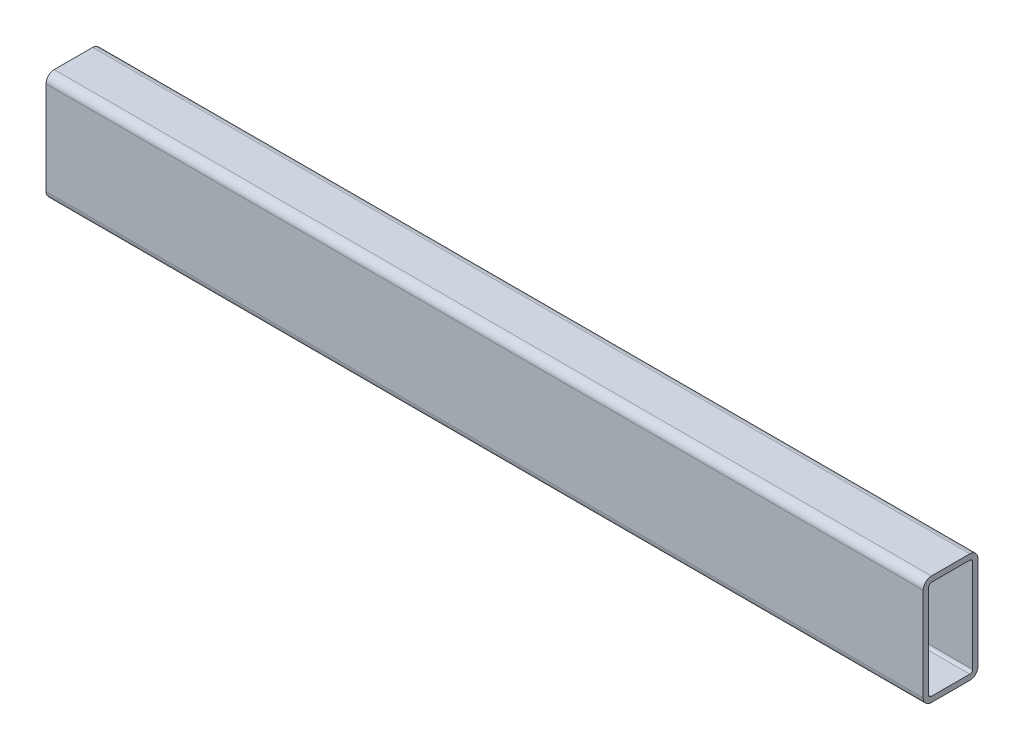
from build123d import *

# Parameters (mm, degrees)
EXTRUDE_1_DEPTH = 320


with BuildPart() as part:
    # Эскиз1 → Вытянуть-Тонкостенный1 (new body)
    with BuildSketch(Plane(origin=(0, 0, 0), x_dir=(0, 0, -1), z_dir=(1, 0, 0))):
        with BuildLine():
            Line((-2, 35), (-2, 1))
            ThreePointArc((-2, 1), (-1.121320344, -1.121320344), (1, -2))
            Line((1, -2), (15, -2))
            ThreePointArc((15, -2), (17.121320344, -1.121320344), (18, 1))
            Line((18, 1), (18, 35))
            ThreePointArc((18, 35), (17.121320344, 37.121320344), (15, 38))
            Line((15, 38), (1, 38))
            ThreePointArc((1, 38), (-1.121320344, 37.121320344), (-2, 35))
        make_face()
        with BuildLine():
            Line((0, 35), (0, 1))
            ThreePointArc((0, 1), (0.292893219, 0.292893219), (1, 0))
            Line((1, 0), (15, 0))
            ThreePointArc((15, 0), (15.707106781, 0.292893219), (16, 1))
            Line((16, 1), (16, 35))
            ThreePointArc((16, 35), (15.707106781, 35.707106781), (15, 36))
            Line((15, 36), (1, 36))
            ThreePointArc((1, 36), (0.292893219, 35.707106781), (0, 35))
        make_face(mode=Mode.SUBTRACT)
    extrude(amount=EXTRUDE_1_DEPTH)


solid = part.part
